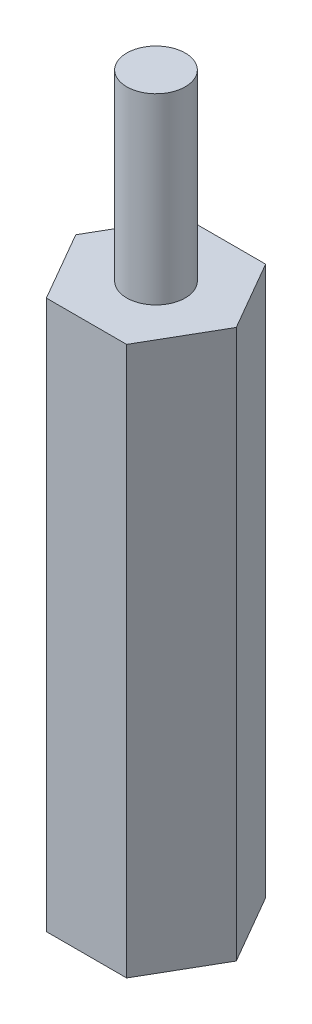
from build123d import *

# Parameters (mm, degrees)
BOSS_EXTRUDE1_DEPTH = 19.05
SKETCH2_R           = 1.016
BOSS_EXTRUDE2_DEPTH = 6.35
SKETCH3_R           = 1.016
CUT_EXTRUDE1_DEPTH  = 6.35


with BuildPart() as part:
    # Sketch1 → Boss-Extrude1 (new body)
    with BuildSketch(Plane(origin=(0, 0, 0), x_dir=(1, 0, 0), z_dir=(0, 1, 0))):
        Polygon((1.3931462, -2.413), (2.786292399, 0), (1.3931462, 2.413), (-1.3931462, 2.413), (-2.786292399, 0), (-1.3931462, -2.413), align=None)
    extrude(amount=BOSS_EXTRUDE1_DEPTH)

    # Sketch2 → Boss-Extrude2 (add)
    with BuildSketch(Plane(origin=(0, 19.05, 0), x_dir=(1, 0, 0), z_dir=(0, 1, 0))):
        Circle(SKETCH2_R)
    extrude(amount=BOSS_EXTRUDE2_DEPTH)

    # Sketch3 → Cut-Extrude1 (cut)
    with BuildSketch(Plane.XZ):
        Circle(SKETCH3_R)
    extrude(amount=-CUT_EXTRUDE1_DEPTH, mode=Mode.SUBTRACT)


solid = part.part
